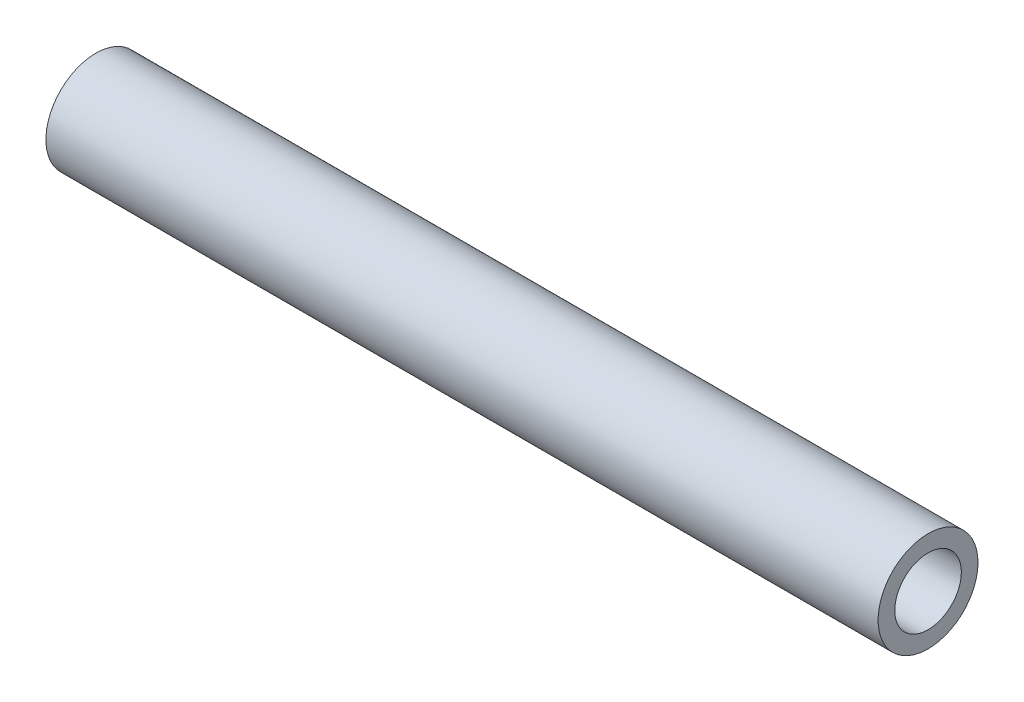
from build123d import *

# Parameters (mm, degrees)
ESBO_O1_R                = 6
ESBO_O1_R_2              = 4
RESSALTO_EXTRUS_O1_DEPTH = 50


with BuildPart() as part:
    # Esboço1 → Ressalto-extrusão1 (new body, symmetric)
    with BuildSketch(Plane(origin=(0, 0, 0), x_dir=(0, 0, -1), z_dir=(1, 0, 0))):
        Circle(ESBO_O1_R)
        Circle(ESBO_O1_R_2, mode=Mode.SUBTRACT)
    extrude(amount=RESSALTO_EXTRUS_O1_DEPTH, both=True)


solid = part.part
